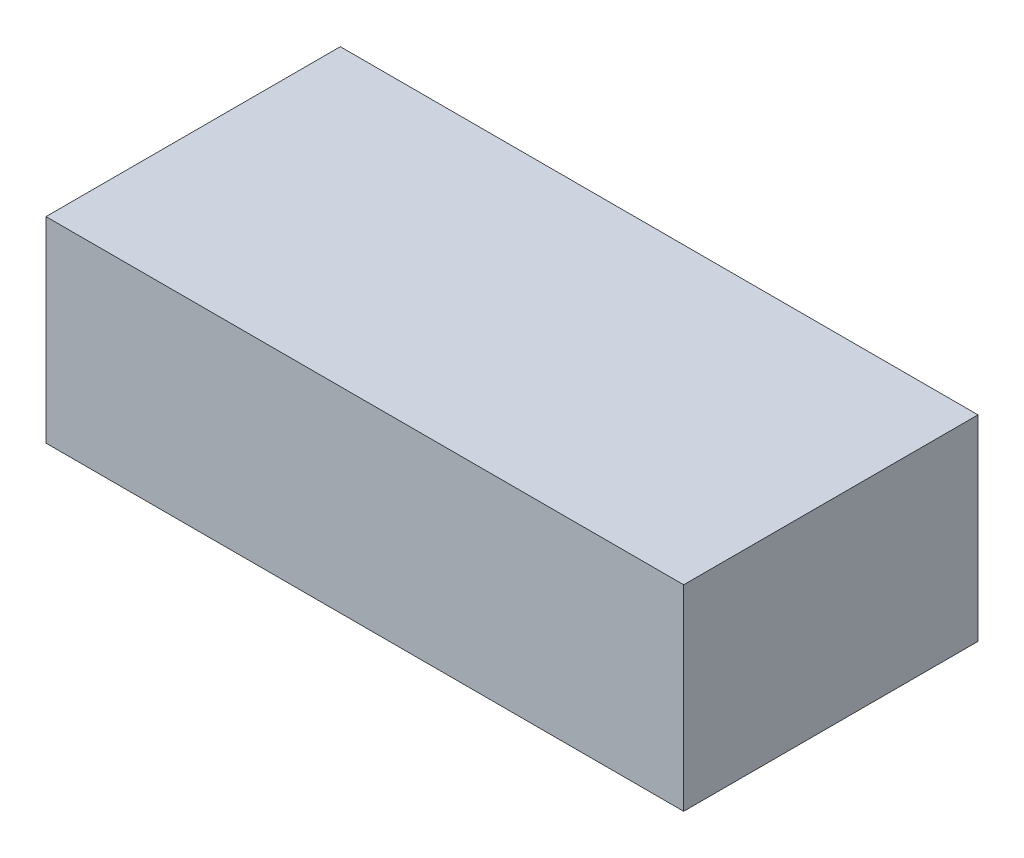
from build123d import *

# Parameters (mm, degrees)
SKETCH1_W      = 16.51
SKETCH1_H      = 7.62
EXTRUDE1_DEPTH = 5.08


with BuildPart() as part:
    # Sketch1 → Extrude1 (new body)
    with BuildSketch(Plane(origin=(0, 0, 0), x_dir=(1, 0, 0), z_dir=(0, 1, 0))):
        Rectangle(SKETCH1_W, SKETCH1_H)
    extrude(amount=EXTRUDE1_DEPTH)


solid = part.part
